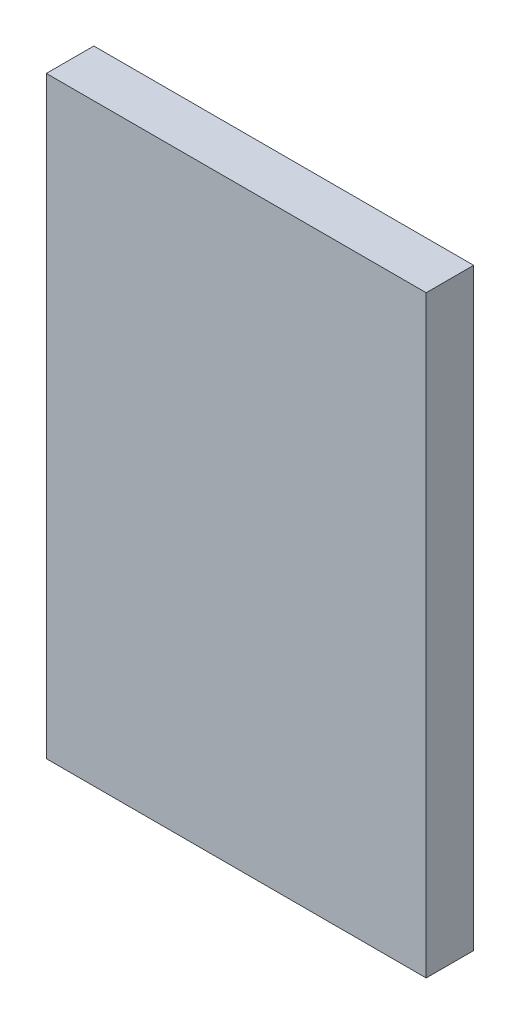
from build123d import *

# Parameters (mm, degrees)
CROQUIS1_W              = 80
CROQUIS1_H              = 125
SALIENTE_EXTRUIR1_DEPTH = 10


with BuildPart() as part:
    # Croquis1 → Saliente-Extruir1 (new body)
    with BuildSketch(Plane.XY):
        with Locations((40, 62.5)):
            Rectangle(CROQUIS1_W, CROQUIS1_H)
    extrude(amount=SALIENTE_EXTRUIR1_DEPTH)


solid = part.part
